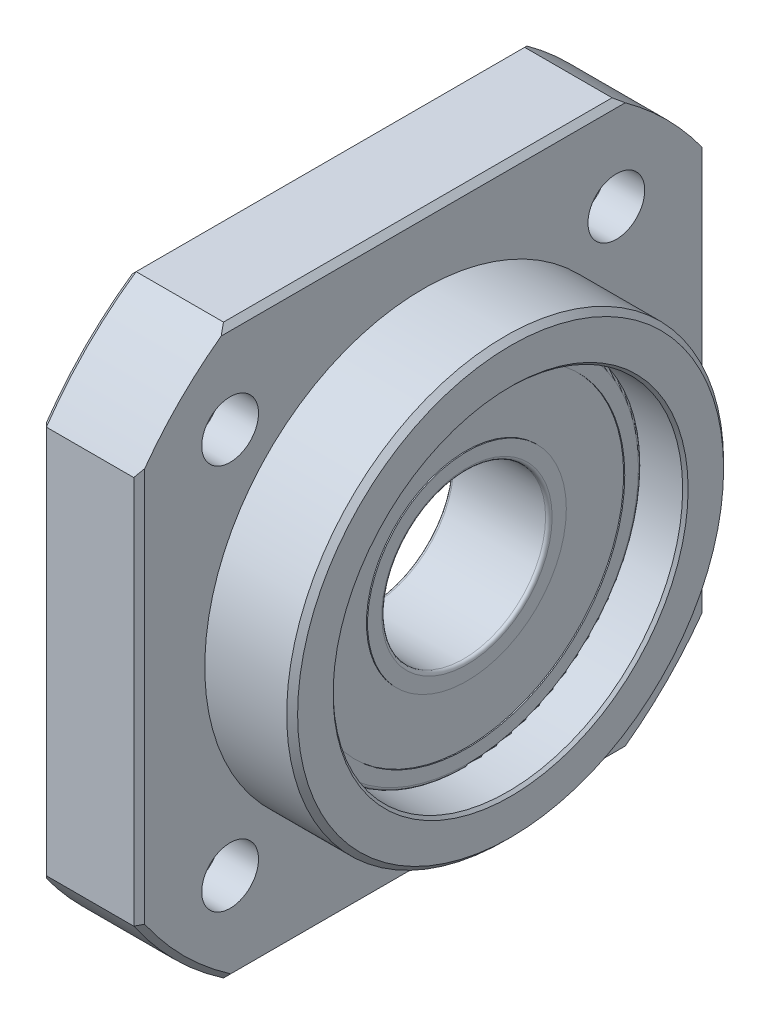
from build123d import *

# Parameters (mm, degrees)
SKIZZE1_W                       = 52
SKIZZE1_H                       = 52
AUFSATZ_LINEAR_AUSTRAGEN1_DEPTH = 17
SKIZZE2_R                       = 63
SKIZZE2_R_2                     = 31.5
SCHNITT_LINEAR_AUSTRAGEN1_DEPTH = 17
SKIZZE3_R                       = 63
SKIZZE3_R_2                     = 20
SCHNITT_LINEAR_AUSTRAGEN2_DEPTH = 8
SKIZZE4_R                       = 16
SCHNITT_LINEAR_AUSTRAGEN3_DEPTH = 17
SKIZZE5_R                       = 2.6
SCHNITT_LINEAR_AUSTRAGEN4_DEPTH = 9
LINEARES_MUSTER1_COUNT          = 2
LINEARES_MUSTER1_PITCH          = 35.355339059
LINEARES_MUSTER1_COUNT_DIR2     = 2
LINEARES_MUSTER1_PITCH_DIR2     = 35.355339059
SKIZZE7_R                       = 4.75
SCHNITT_LINEAR_AUSTRAGEN5_DEPTH = 5.4
LINEARES_MUSTER2_COUNT          = 2
LINEARES_MUSTER2_PITCH          = 35.355339059
LINEARES_MUSTER2_COUNT_DIR2     = 2
LINEARES_MUSTER2_PITCH_DIR2     = 35.355339059
FASE1_SIZE                      = 0.5
FASE2_SIZE                      = 0.5
FASE3_SIZE                      = 0.25


with BuildPart() as part:
    # Skizze1 → Aufsatz-Linear austragen1 (new body)
    with BuildSketch(Plane(origin=(0, 0, 0), x_dir=(0, 0, -1), z_dir=(1, 0, 0))):
        Rectangle(SKIZZE1_W, SKIZZE1_H)
    extrude(amount=AUFSATZ_LINEAR_AUSTRAGEN1_DEPTH)

    # Skizze2 → Schnitt-Linear austragen1 (cut)
    with BuildSketch(Plane(origin=(0, 0, 0), x_dir=(0, 0, -1), z_dir=(1, 0, 0))):
        Circle(SKIZZE2_R)
        Circle(SKIZZE2_R_2, mode=Mode.SUBTRACT)
    extrude(amount=SCHNITT_LINEAR_AUSTRAGEN1_DEPTH, mode=Mode.SUBTRACT)

    # Skizze3 → Schnitt-Linear austragen2 (cut)
    with BuildSketch(Plane(origin=(9, 0, 0), x_dir=(0, 0, -1), z_dir=(1, 0, 0))):
        Circle(SKIZZE3_R)
        Circle(SKIZZE3_R_2, mode=Mode.SUBTRACT)
    extrude(amount=SCHNITT_LINEAR_AUSTRAGEN2_DEPTH, mode=Mode.SUBTRACT)

    # Skizze4 → Schnitt-Linear austragen3 (cut)
    with BuildSketch(Plane(origin=(0, 0, 0), x_dir=(0, 0, -1), z_dir=(1, 0, 0))):
        Circle(SKIZZE4_R)
    extrude(amount=SCHNITT_LINEAR_AUSTRAGEN3_DEPTH, mode=Mode.SUBTRACT)

    # Skizze5 → Schnitt-Linear austragen4 (cut)
    with BuildSketch(Plane(origin=(0, 0, 0), x_dir=(0, 0, -1), z_dir=(1, 0, 0))):
        with Locations((-17.67766953, 17.67766953)):
            Circle(SKIZZE5_R)
    schnitt_linear_austragen4 = extrude(amount=SCHNITT_LINEAR_AUSTRAGEN4_DEPTH, mode=Mode.SUBTRACT)

    # Lineares Muster1: Schnitt-Linear austragen4 2 × 2
    with Locations(*[(0, -j * LINEARES_MUSTER1_PITCH_DIR2, -i * LINEARES_MUSTER1_PITCH) for i in range(LINEARES_MUSTER1_COUNT) for j in range(LINEARES_MUSTER1_COUNT_DIR2) if (i, j) != (0, 0)]):
        add(schnitt_linear_austragen4, mode=Mode.SUBTRACT)

    # Skizze7 → Schnitt-Linear austragen5 (cut)
    with BuildSketch(Plane(origin=(0, 0, 0), x_dir=(0, 0, -1), z_dir=(1, 0, 0))):
        with Locations((-17.67766953, 17.67766953)):
            Circle(SKIZZE7_R)
    schnitt_linear_austragen5 = extrude(amount=SCHNITT_LINEAR_AUSTRAGEN5_DEPTH, mode=Mode.SUBTRACT)

    # Lineares Muster2: Schnitt-Linear austragen5 2 × 2
    with Locations(*[(0, -j * LINEARES_MUSTER2_PITCH_DIR2, -i * LINEARES_MUSTER2_PITCH) for i in range(LINEARES_MUSTER2_COUNT) for j in range(LINEARES_MUSTER2_COUNT_DIR2) if (i, j) != (0, 0)]):
        add(schnitt_linear_austragen5, mode=Mode.SUBTRACT)

    # Skizze9 → Rotation1 (revolve)
    with BuildSketch(Plane(origin=(0, 0, 0), x_dir=(-1, 0, 0), z_dir=(0, 0, -1)), mode=Mode.PRIVATE) as rotation1_sk:
        with BuildLine():
            Line((-13, 15.7), (-13, 14.45))
            Line((-13, 14.45), (-12.9, 14.45))
            Line((-12.9, 14.45), (-12.9, 9.1))
            Line((-12.9, 9.1), (-13, 9.1))
            Line((-13, 9.1), (-13, 7.8))
            ThreePointArc((-13, 7.8), (-12.912132034, 7.587867966), (-12.7, 7.5))
            Line((-12.7, 7.5), (-4.3, 7.5))
            ThreePointArc((-4.3, 7.5), (-4.087867966, 7.587867966), (-4, 7.8))
            Line((-4, 7.8), (-4, 9.1))
            Line((-4, 9.1), (-4.1, 9.1))
            Line((-4.1, 9.1), (-4.1, 14.45))
            Line((-4.1, 14.45), (-4, 14.45))
            Line((-4, 14.45), (-4, 15.7))
            ThreePointArc((-4, 15.7), (-4.087867966, 15.912132034), (-4.3, 16))
            Line((-4.3, 16), (-12.7, 16))
            ThreePointArc((-12.7, 16), (-12.912132034, 15.912132034), (-13, 15.7))
        make_face()
    revolve(rotation1_sk.sketch.rotate(Axis((-500, 0, 0), (1, 0, 0)), 270), axis=Axis((-500, 0, 0), (1, 0, 0)))  # turned: the seam where the file's is

    # Fase1
    fase1_edges = [part.edges().sort_by_distance(p)[0] for p in [
        (17, 0, 20),
    ]]
    chamfer(fase1_edges, length=FASE1_SIZE)

    # Fase2
    fase2_edges = [part.edges().sort_by_distance(p)[0] for p in [
        (0, -26, 0),
        (0, 0, -26),
        (9, 0, 26),
        (9, -22.273863607, 22.273863607),
        (9, -26, 0),
        (9, 0, -26),
        (9, 26, 0),
        (0, 0, 26),
        (0, 26, 0),
        (0, 22.273863607, 22.273863607),
    ]]
    chamfer(fase2_edges, length=FASE2_SIZE)

    # Fase3
    fase3_edges = [part.edges().sort_by_distance(p)[0] for p in [
        (0, 0, 16),
        (17, 0, 16),
    ]]
    chamfer(fase3_edges, length=FASE3_SIZE)


solid = part.part
